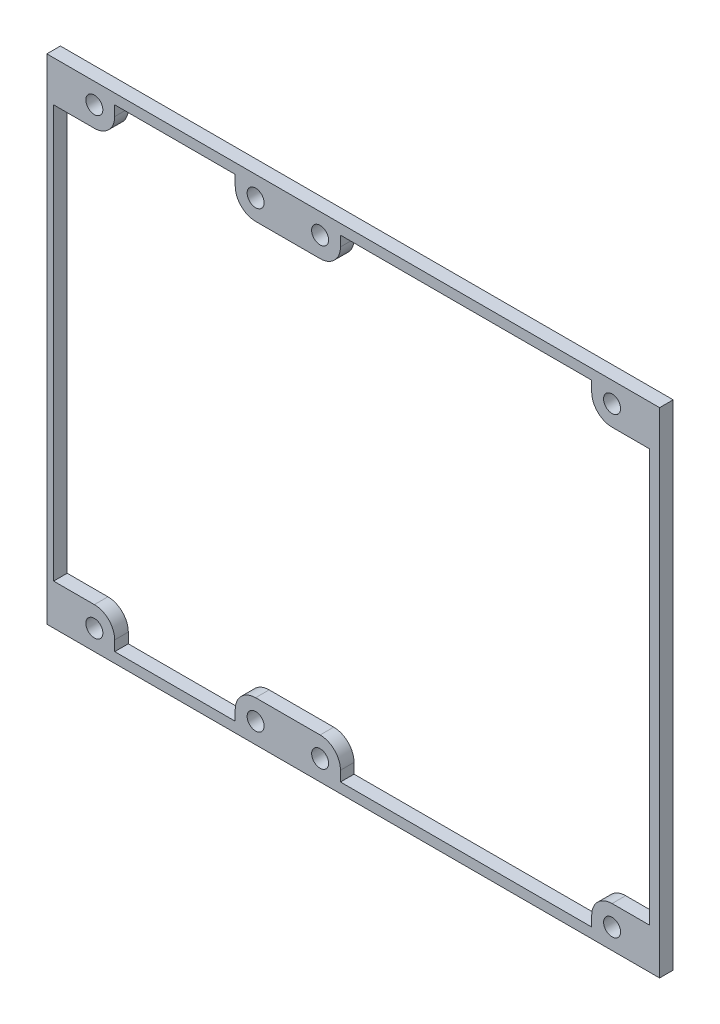
from build123d import *

# Parameters (mm, degrees)
SKETCH2_W           = 180.5
SKETCH2_H           = 145.5
BOSS_EXTRUDE1_DEPTH = 4
CUT_EXTRUDE2_REACH  = 6
SKETCH5_R           = 2.5


with BuildPart() as part:
    # Sketch2 → Boss-Extrude1 (new body)
    with BuildSketch(Plane.XY):
        Rectangle(SKETCH2_W, SKETCH2_H)
    extrude(amount=BOSS_EXTRUDE1_DEPTH)

    # Sketch5 → Cut-Extrude2 (cut, up to next)
    with BuildSketch(Plane.XY.offset(4), mode=Mode.PRIVATE) as cut_extrude2_sk1:
        with Locations((-76.25, 66.75)):
            Circle(SKETCH5_R)
    cut_extrude2_tool1 = extrude(cut_extrude2_sk1.sketch, amount=-CUT_EXTRUDE2_REACH, mode=Mode.PRIVATE) & part.part
    add(cut_extrude2_tool1.solids().sort_by_distance((-76.25, 66.75, 4))[0], mode=Mode.SUBTRACT)
    # Sketch5 → Cut-Extrude2 (cut, up to next)
    with BuildSketch(Plane.XY.offset(4), mode=Mode.PRIVATE) as cut_extrude2_sk2:
        with Locations((-28.75, 66.75)):
            Circle(SKETCH5_R)
    cut_extrude2_tool2 = extrude(cut_extrude2_sk2.sketch, amount=-CUT_EXTRUDE2_REACH, mode=Mode.PRIVATE) & part.part
    add(cut_extrude2_tool2.solids().sort_by_distance((-28.75, 66.75, 4))[0], mode=Mode.SUBTRACT)
    # Sketch5 → Cut-Extrude2 (cut, up to next)
    with BuildSketch(Plane.XY.offset(4), mode=Mode.PRIVATE) as cut_extrude2_sk3:
        with Locations((-9.75, 66.75)):
            Circle(SKETCH5_R)
    cut_extrude2_tool3 = extrude(cut_extrude2_sk3.sketch, amount=-CUT_EXTRUDE2_REACH, mode=Mode.PRIVATE) & part.part
    add(cut_extrude2_tool3.solids().sort_by_distance((-9.75, 66.75, 4))[0], mode=Mode.SUBTRACT)
    # Sketch5 → Cut-Extrude2 (cut, up to next)
    with BuildSketch(Plane.XY.offset(4), mode=Mode.PRIVATE) as cut_extrude2_sk4:
        with Locations((76.25, 66.75)):
            Circle(SKETCH5_R)
    cut_extrude2_tool4 = extrude(cut_extrude2_sk4.sketch, amount=-CUT_EXTRUDE2_REACH, mode=Mode.PRIVATE) & part.part
    add(cut_extrude2_tool4.solids().sort_by_distance((76.25, 66.75, 4))[0], mode=Mode.SUBTRACT)
    # Sketch5 → Cut-Extrude2 (cut, up to next)
    with BuildSketch(Plane.XY.offset(4), mode=Mode.PRIVATE) as cut_extrude2_sk5:
        with Locations((76.25, -66.75)):
            Circle(SKETCH5_R)
    cut_extrude2_tool5 = extrude(cut_extrude2_sk5.sketch, amount=-CUT_EXTRUDE2_REACH, mode=Mode.PRIVATE) & part.part
    add(cut_extrude2_tool5.solids().sort_by_distance((76.25, -66.75, 4))[0], mode=Mode.SUBTRACT)
    # Sketch5 → Cut-Extrude2 (cut, up to next)
    with BuildSketch(Plane.XY.offset(4), mode=Mode.PRIVATE) as cut_extrude2_sk6:
        with Locations((-9.75, -66.75)):
            Circle(SKETCH5_R)
    cut_extrude2_tool6 = extrude(cut_extrude2_sk6.sketch, amount=-CUT_EXTRUDE2_REACH, mode=Mode.PRIVATE) & part.part
    add(cut_extrude2_tool6.solids().sort_by_distance((-9.75, -66.75, 4))[0], mode=Mode.SUBTRACT)
    # Sketch5 → Cut-Extrude2 (cut, up to next)
    with BuildSketch(Plane.XY.offset(4), mode=Mode.PRIVATE) as cut_extrude2_sk7:
        with Locations((-28.75, -66.75)):
            Circle(SKETCH5_R)
    cut_extrude2_tool7 = extrude(cut_extrude2_sk7.sketch, amount=-CUT_EXTRUDE2_REACH, mode=Mode.PRIVATE) & part.part
    add(cut_extrude2_tool7.solids().sort_by_distance((-28.75, -66.75, 4))[0], mode=Mode.SUBTRACT)
    # Sketch5 → Cut-Extrude2 (cut, up to next)
    with BuildSketch(Plane.XY.offset(4), mode=Mode.PRIVATE) as cut_extrude2_sk8:
        with Locations((-76.25, -66.75)):
            Circle(SKETCH5_R)
    cut_extrude2_tool8 = extrude(cut_extrude2_sk8.sketch, amount=-CUT_EXTRUDE2_REACH, mode=Mode.PRIVATE) & part.part
    add(cut_extrude2_tool8.solids().sort_by_distance((-76.25, -66.75, 4))[0], mode=Mode.SUBTRACT)
    # Sketch5 → Cut-Extrude2 (cut, up to next)
    with BuildSketch(Plane.XY.offset(4), mode=Mode.PRIVATE) as cut_extrude2_sk9:
        with BuildLine():
            Line((-70.25, 69.75), (-34.75, 69.75))
            Line((-34.75, 69.75), (-34.75, 66.75))
            ThreePointArc((-34.75, 66.75), (-32.992640687, 62.507359313), (-28.75, 60.75))
            Line((-28.75, 60.75), (-9.75, 60.75))
            ThreePointArc((-9.75, 60.75), (-5.507359313, 62.507359313), (-3.75, 66.75))
            Line((-3.75, 66.75), (-3.75, 69.75))
            Line((-3.75, 69.75), (70.25, 69.75))
            Line((70.25, 69.75), (70.25, 66.75))
            ThreePointArc((70.25, 66.75), (72.007359313, 62.507359313), (76.25, 60.75))
            Line((76.25, 60.75), (87.25, 60.75))
            Line((87.25, 60.75), (87.25, -60.75))
            Line((87.25, -60.75), (76.25, -60.75))
            ThreePointArc((76.25, -60.75), (72.007359313, -62.507359313), (70.25, -66.75))
            Line((70.25, -66.75), (70.25, -69.75))
            Line((70.25, -69.75), (-3.75, -69.75))
            Line((-3.75, -69.75), (-3.75, -66.75))
            ThreePointArc((-3.75, -66.75), (-5.507359313, -62.507359313), (-9.75, -60.75))
            Line((-9.75, -60.75), (-28.75, -60.75))
            ThreePointArc((-28.75, -60.75), (-32.992640687, -62.507359313), (-34.75, -66.75))
            Line((-34.75, -66.75), (-34.75, -69.75))
            Line((-34.75, -69.75), (-70.25, -69.75))
            Line((-70.25, -69.75), (-70.25, -66.75))
            ThreePointArc((-70.25, -66.75), (-72.007359313, -62.507359313), (-76.25, -60.75))
            Line((-76.25, -60.75), (-88.25, -60.75))
            Line((-88.25, -60.75), (-88.25, 60.75))
            Line((-88.25, 60.75), (-76.25, 60.75))
            ThreePointArc((-76.25, 60.75), (-72.007359313, 62.507359313), (-70.25, 66.75))
            Line((-70.25, 66.75), (-70.25, 69.75))
        make_face()
    cut_extrude2_tool9 = extrude(cut_extrude2_sk9.sketch, amount=-CUT_EXTRUDE2_REACH, mode=Mode.PRIVATE) & part.part
    add(cut_extrude2_tool9.solids().sort_by_distance((-0.02205, 0, 4))[0], mode=Mode.SUBTRACT)


solid = part.part
